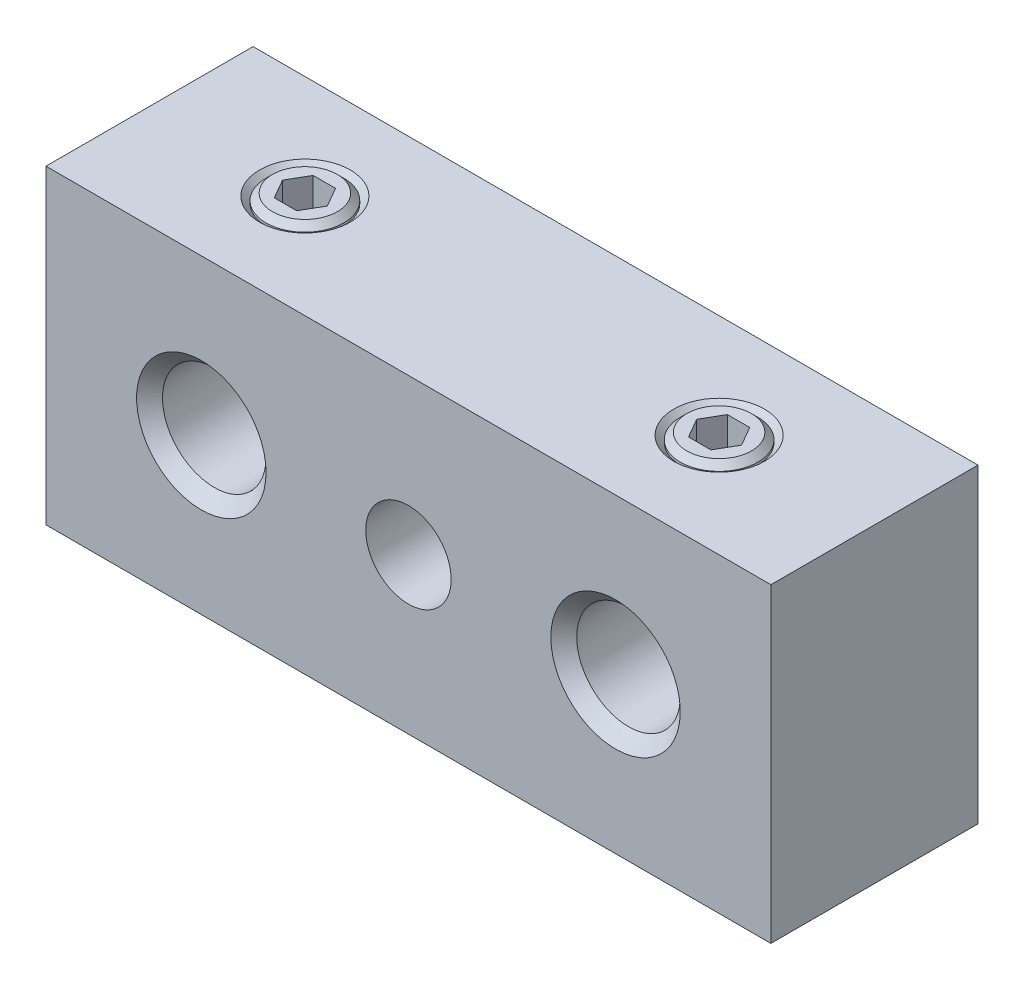
from build123d import *

# Parameters (mm, degrees)
SKETCH1_W               = 14
SKETCH1_H               = 12
BOSS_EXTRUDE1_DEPTH     = 4
CUT_EXTRUDE1_DEPTH      = 16.748015748
CUT_EXTRUDE1_DEPTH_BACK = 16.748015748
SKETCH2_R               = 2
SKETCH3_R               = 1.65
CUT_EXTRUDE2_DEPTH      = 18.204650534
SKETCH4_R               = 1.25
CUT_EXTRUDE3_DEPTH      = 16.748015748
SKETCH5_R               = 1.5
BOSS_EXTRUDE2_DEPTH     = 4.6
CHAMFER1_SIZE           = 0.25
CHAMFER2_SIZE           = 0.5
CUT_EXTRUDE4_DEPTH      = 2


with BuildPart() as part:
    # Sketch1 → Boss-Extrude1 (new, symmetric)
    with BuildSketch(Plane.XY):
        with Locations((7, 0)):
            Rectangle(SKETCH1_W, SKETCH1_H)
    extrude(amount=BOSS_EXTRUDE1_DEPTH, both=True)

    # Sketch2 → Cut-Extrude1 (cut, two sides: drawn at the far end of the back side and taken through both)
    with BuildSketch(Plane.XY.offset(-CUT_EXTRUDE1_DEPTH_BACK)):
        with Locations((8, 0)):
            Circle(SKETCH2_R)
    extrude(amount=CUT_EXTRUDE1_DEPTH + CUT_EXTRUDE1_DEPTH_BACK, mode=Mode.SUBTRACT)

    # Sketch3 → Cut-Extrude2 (cut, through all)
    with BuildSketch(Plane.XY.offset(4)):
        Circle(SKETCH3_R)
    extrude(amount=-CUT_EXTRUDE2_DEPTH, mode=Mode.SUBTRACT)

    # Sketch4 → Cut-Extrude3 (cut, through all)
    with BuildSketch(Plane(origin=(0, 0, 0), x_dir=(1, 0, 0), z_dir=(0, 1, 0))):
        with Locations((8, 0)):
            Circle(SKETCH4_R)
    extrude(amount=CUT_EXTRUDE3_DEPTH, mode=Mode.SUBTRACT)

    # Chamfer2
    chamfer2_edges = [part.edges().sort_by_distance(p)[0] for p in [
        (6, 0, -4),
        (6, 0, 4),
        (6.75, 6, 0),
    ]]
    chamfer(chamfer2_edges, length=CHAMFER2_SIZE)


with BuildPart() as body_2:
    # Sketch5 → Boss-Extrude2 (new body)
    with BuildSketch(Plane(origin=(0, 1.5, 0), x_dir=(1, 0, 0), z_dir=(0, 1, 0))):
        with Locations((8, 0)):
            Circle(SKETCH5_R)
    extrude(amount=BOSS_EXTRUDE2_DEPTH)

    # Chamfer1
    chamfer1_edges = [body_2.edges().sort_by_distance(p)[0] for p in [
        (6.5, 6.1, 0),
    ]]
    chamfer(chamfer1_edges, length=CHAMFER1_SIZE)

    # Sketch6 → Cut-Extrude4 (cut)
    with BuildSketch(Plane(origin=(0, 6.1, 0), x_dir=(1, 0, 0), z_dir=(0, 1, 0))):
        Polygon((7.133974596, 0), (7.566987298, -0.75), (8.433012702, -0.75), (8.866025404, 0), (8.433012702, 0.75), (7.566987298, 0.75), align=None)
    extrude(amount=-CUT_EXTRUDE4_DEPTH, mode=Mode.SUBTRACT)


with BuildPart() as body_3:
    # Mirror1: mirrored copy
    add(part.part.mirror(Plane(origin=(0, 0, 0), x_dir=(0, 0, 1), z_dir=(1, 0, 0))))

    # Combine1: union part
    add(part.part)


with BuildPart() as body_4:
    # Mirror1 2: mirrored copy
    add(body_2.part.mirror(Plane(origin=(0, 0, 0), x_dir=(0, 0, 1), z_dir=(1, 0, 0))))


solid = Compound([body_2.part, body_3.part, body_4.part])
